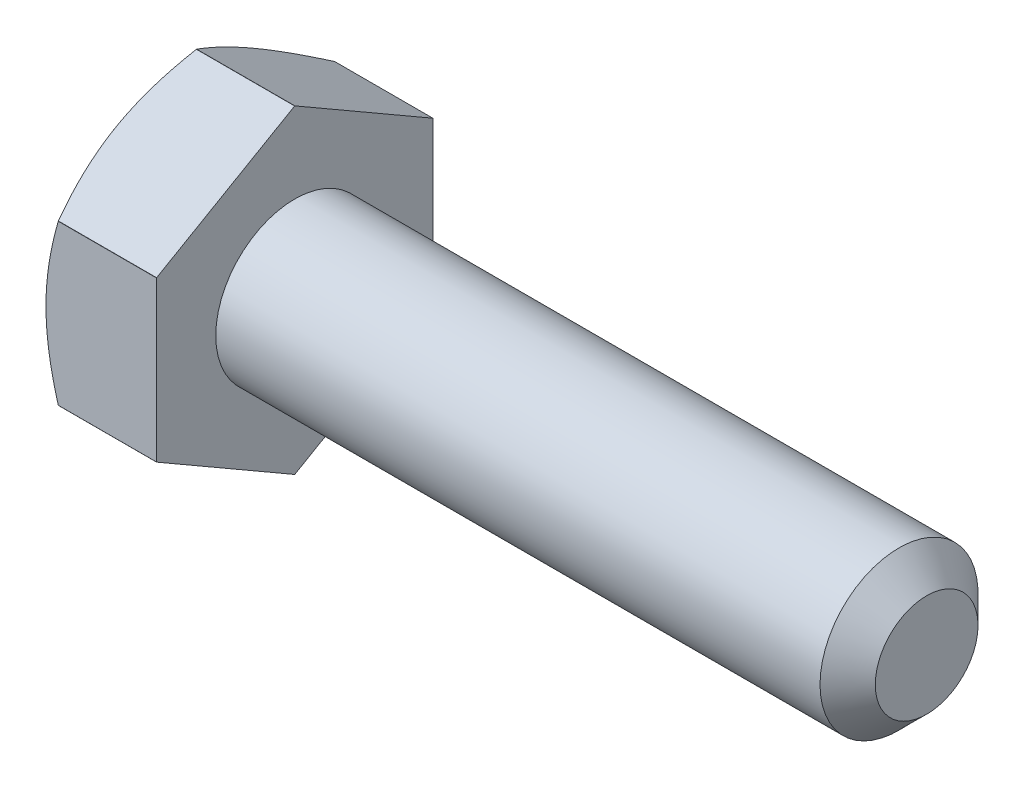
from build123d import *

# Parameters (mm, degrees)
SKETCH_2_OUTSIDE_W  = 14.48
SKETCH_2_OUTSIDE_H  = 14.48
CUT_EXTRUDE_1_DEPTH = 18.8
CHAMFER_1_SIZE      = 0.7


with BuildPart() as part:
    # Эскиз1 → Повернуть1 (revolve)
    with BuildSketch(Plane.XY):
        Polygon((-12.8, 0), (-12.8, 4.04), (-10, 4.04), (-10, 2), (6, 2), (6, 0), align=None)
    revolve(axis=Axis((-21.700276243, 0, 0), (1, 0, 0)))

    # Эскиз2 outside → Вырез-Вытянуть1 (cut)
    with BuildSketch(Plane.ZY.offset(12.8)):
        Rectangle(SKETCH_2_OUTSIDE_W, SKETCH_2_OUTSIDE_H)
        Polygon((0, 4.041451884), (-3.5, 2.020725942), (-3.5, -2.020725942), (0, -4.041451884), (3.5, -2.020725942), (3.5, 2.020725942), align=None, mode=Mode.SUBTRACT)
    extrude(amount=-CUT_EXTRUDE_1_DEPTH, mode=Mode.SUBTRACT)

    # Фаска1
    chamfer_1_edges = [part.edges().sort_by_distance(p)[0] for p in [
        (6, -2, 0),
    ]]
    chamfer(chamfer_1_edges, length=CHAMFER_1_SIZE)

    # Эскиз5 → Вырез-Повернуть1 (revolve, cut)
    with BuildSketch(Plane(origin=(0, 0, 0), x_dir=(-1, 0, 0), z_dir=(0, 0.5, -0.866025404))):
        Polygon((12.8, 3.497483906), (12.8, 6.497483906), (11.067949192, 6.497483906), align=None)
    revolve(axis=Axis((0, 0, 0), (-1, 0, 0)), mode=Mode.SUBTRACT)


solid = part.part
